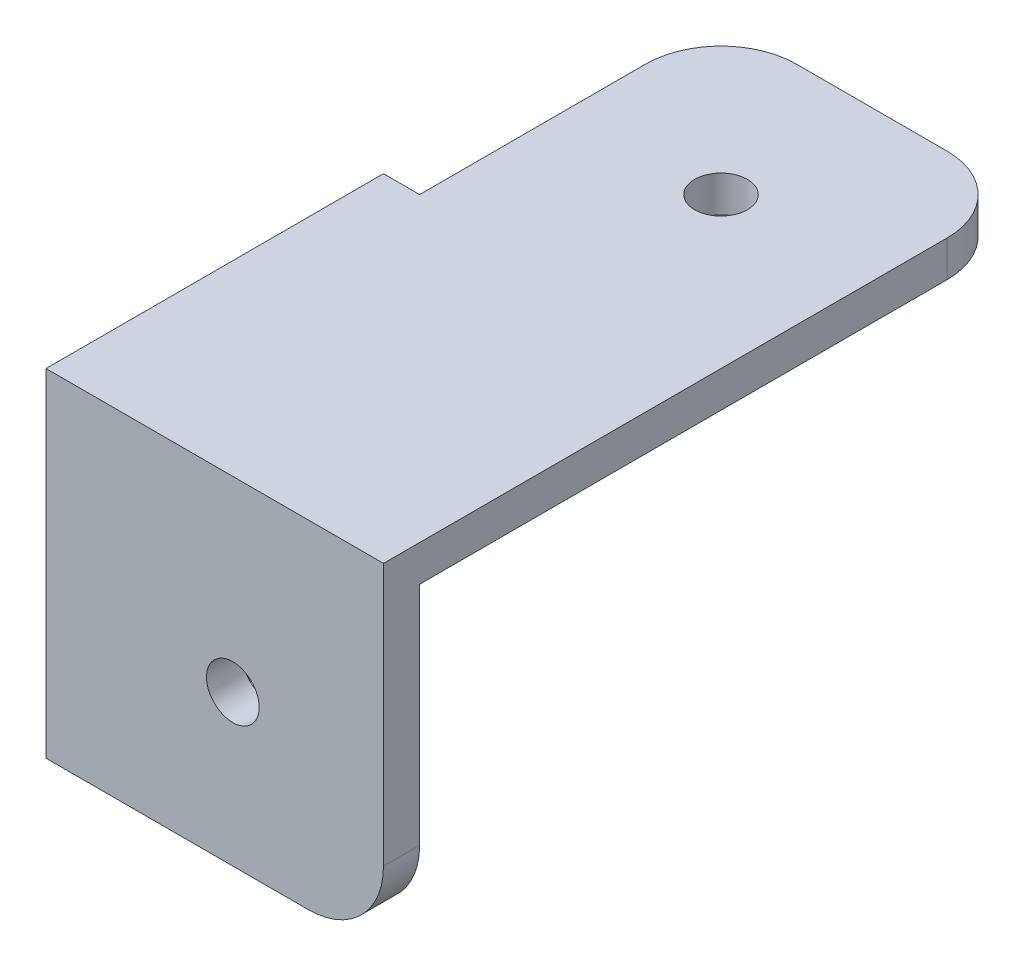
from build123d import *

# Parameters (mm, degrees)
SKETCH1_W           = 2.4
SKETCH1_H           = 20
SKETCH1_H_2         = 2.4
SKETCH1_W_2         = 20
BOSS_EXTRUDE1_DEPTH = 20
BOSS_EXTRUDE2_DEPTH = 2.4
CUT_EXTRUDE1_REACH  = 4.4
SKETCH4_R           = 1.75
CUT_EXTRUDE2_REACH  = 4.4
SKETCH5_R           = 1.75
CUT_EXTRUDE3_REACH  = 24.4
SKETCH6_R           = 1.75
SKETCH7_R           = 2
BOSS_EXTRUDE3_DEPTH = 5
FILLET1_R           = 5


with BuildPart() as part:
    # Sketch1 → Boss-Extrude1 (new body)
    with BuildSketch(Plane(origin=(0, 0, 0), x_dir=(1, 0, 0), z_dir=(0, 1, 0))):
        with Locations((-1.2, 10)):
            Rectangle(SKETCH1_W, SKETCH1_H)
        with Locations((-1.2, -1.2)):
            Rectangle(SKETCH1_W, SKETCH1_H_2)
        with Locations((10, -1.2)):
            Rectangle(SKETCH1_W_2, SKETCH1_H_2)
    extrude(amount=-BOSS_EXTRUDE1_DEPTH)

    # Sketch2 → Boss-Extrude2 (add)
    with BuildSketch(Plane(origin=(0, 0, 0), x_dir=(1, 0, 0), z_dir=(0, 1, 0))):
        Polygon((20, -2.4), (20, 40), (0, 40), (0, 20), (-2.4, 20), (-2.4, -2.4), align=None)
    extrude(amount=BOSS_EXTRUDE2_DEPTH)

    # Sketch4 → Cut-Extrude1 (cut, up to next)
    with BuildSketch(Plane(origin=(0, 0, 0), x_dir=(0, 0, -1), z_dir=(1, 0, 0)), mode=Mode.PRIVATE) as cut_extrude1_sk1:
        with Locations((10, -10)):
            Circle(SKETCH4_R)
    cut_extrude1_tool1 = extrude(cut_extrude1_sk1.sketch, amount=-CUT_EXTRUDE1_REACH, mode=Mode.PRIVATE) & part.part
    add(cut_extrude1_tool1.solids().sort_by_distance((0, -10, -10))[0], mode=Mode.SUBTRACT)

    # Sketch5 → Cut-Extrude2 (cut, up to next)
    with BuildSketch(Plane(origin=(0, 0, 0), x_dir=(-1, 0, 0), z_dir=(0, 0, -1)), mode=Mode.PRIVATE) as cut_extrude2_sk1:
        with Locations((-10, -10)):
            Circle(SKETCH5_R)
    cut_extrude2_tool1 = extrude(cut_extrude2_sk1.sketch, amount=-CUT_EXTRUDE2_REACH, mode=Mode.PRIVATE) & part.part
    add(cut_extrude2_tool1.solids().sort_by_distance((10, -10, 0))[0], mode=Mode.SUBTRACT)

    # Sketch6 → Cut-Extrude3 (cut, up to next)
    with BuildSketch(Plane(origin=(0, 2.4, 0), x_dir=(1, 0, 0), z_dir=(0, 1, 0)), mode=Mode.PRIVATE) as cut_extrude3_sk1:
        with Locations((10, 30)):
            Circle(SKETCH6_R)
    cut_extrude3_tool1 = extrude(cut_extrude3_sk1.sketch, amount=-CUT_EXTRUDE3_REACH, mode=Mode.PRIVATE) & part.part
    add(cut_extrude3_tool1.solids().sort_by_distance((10, 2.4, -30))[0], mode=Mode.SUBTRACT)

    # Sketch7 → Boss-Extrude3 (add)
    with BuildSketch(Plane.XZ):
        with Locations((10, -10)):
            Circle(SKETCH7_R)
    extrude(amount=BOSS_EXTRUDE3_DEPTH)

    # Fillet1
    fillet1_edges = [part.edges().sort_by_distance(p)[0] for p in [
        (20, -20, 1.2),
        (20, 1.2, -40),
        (0, 1.2, -40),
        (-1.2, -20, -20),
    ]]
    fillet(fillet1_edges, radius=FILLET1_R)


solid = part.part
